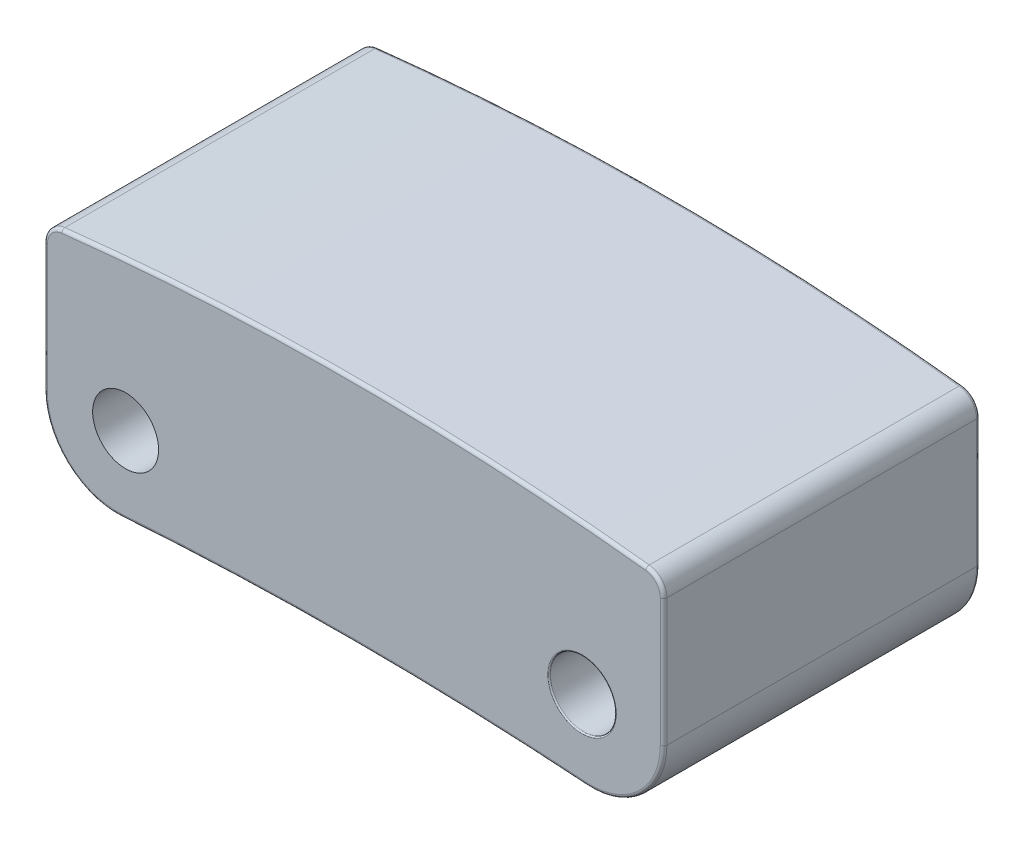
from build123d import *

# Parameters (mm, degrees)
SKETCH1_W               = 9.4
SKETCH1_H               = 3.7
BOSS_EXTRUDE1_DEPTH     = 2.4
CUT_EXTRUDE1_DEPTH      = 4.8
FILLET1_R               = 1.1
FILLET2_R               = 0.3
FILLET3_R               = 0.05
SKETCH3_R               = 0.5
CUT_EXTRUDE2_DEPTH      = 4.8
FILLET4_R               = 0.02
SKETCH4_W               = 1.881576533
SKETCH4_H               = 1.177564348
BOSS_EXTRUDE2_DEPTH     = 1
SKETCH5_R               = 0.5
CUT_EXTRUDE3_DEPTH      = 10
SKETCH6_R               = 0.737542503
BOSS_EXTRUDE3_DEPTH     = 1
CUT_EXTRUDE4_REACH      = 17.585
CUT_EXTRUDE4_END_RADIUS = 50.4
CUT_EXTRUDE4_START      = -10
SKETCH7_R               = 0.4
FILLET5_R               = 0.05


with BuildPart() as part:
    # Sketch1 → Boss-Extrude1 (new, symmetric)
    with BuildSketch(Plane.XY):
        Rectangle(SKETCH1_W, SKETCH1_H)
    extrude(amount=BOSS_EXTRUDE1_DEPTH, both=True)

    # Sketch2 → Cut-Extrude1 (cut)
    with BuildSketch(Plane.XY.offset(2.4)):
        with BuildLine():
            Line((-4.7, 1.55), (-7.120690005, 4.011417256))
            Line((-7.120690005, 4.011417256), (5.535860742, 3.886722174))
            Line((5.535860742, 3.886722174), (4.7, 1.55))
            ThreePointArc((4.7, 1.55), (0, 1.827084699), (-4.7, 1.55))
        make_face()
        with BuildLine():
            Line((4.7, -1.85), (0.350623614, -3.782025322))
            Line((0.350623614, -3.782025322), (-4.7, -1.85))
            ThreePointArc((-4.7, -1.85), (0, -1.628609864), (4.7, -1.85))
        make_face()
    extrude(amount=-CUT_EXTRUDE1_DEPTH, mode=Mode.SUBTRACT)

    # Fillet1
    fillet1_edges = [part.edges().sort_by_distance(p)[0] for p in [
        (4.7, -1.85, 0),
        (-4.7, -1.85, 0),
    ]]
    fillet(fillet1_edges, radius=FILLET1_R)

    # Fillet2
    fillet2_edges = [part.edges().sort_by_distance(p)[0] for p in [
        (4.7, 1.55, 0),
        (-4.7, 1.55, 0),
    ]]
    fillet(fillet2_edges, radius=FILLET2_R)

    # Fillet3
    fillet3_edges = [part.edges().sort_by_distance(p)[0] for p in [
        (4.7, 0.3134624, -2.4),
        (4.7, 0.3134624, 2.4),
        (0, -1.628609864, -2.4),
        (-4.349918456, -1.460327621, -2.4),
        (4.349918456, -1.460327621, -2.4),
        (0, -1.628609864, 2.4),
        (-4.349918456, -1.460327621, 2.4),
        (4.349918456, -1.460327621, 2.4),
        (0, 1.827084699, 2.4),
        (-4.7, 0.3134624, 2.4),
        (-4.623578634, 1.482534062, 2.4),
        (4.623578634, 1.482534062, 2.4),
        (0, 1.827084699, -2.4),
        (-4.7, 0.3134624, -2.4),
        (-4.623578634, 1.482534062, -2.4),
        (4.623578634, 1.482534062, -2.4),
    ]]
    fillet(fillet3_edges, radius=FILLET3_R)

    # Sketch3 → Cut-Extrude2 (cut)
    with BuildSketch(Plane.XY.offset(2.4)):
        with Locations((3.462563269, -0.578744651)):
            Circle(SKETCH3_R)
    cut_extrude2 = extrude(amount=-CUT_EXTRUDE2_DEPTH, mode=Mode.SUBTRACT)

    # Fillet4
    fillet4_edges = [part.edges().sort_by_distance(p)[0] for p in [
        (2.962563269, -0.578744651, -2.4),
        (2.962563269, -0.578744651, 2.4),
    ]]
    fillet(fillet4_edges, radius=FILLET4_R)

    # Mirror1: Cut-Extrude2 across plane
    add(cut_extrude2.mirror(Plane(origin=(0, 0, 0), x_dir=(0, 0, 1), z_dir=(1, 0, 0))), mode=Mode.SUBTRACT)

    # Sketch4 → Boss-Extrude2 (add)
    with BuildSketch(Plane.XY.offset(2.4)):
        with Locations((-3.353123346, -0.588782174)):
            Rectangle(SKETCH4_W, SKETCH4_H)
    extrude(amount=-BOSS_EXTRUDE2_DEPTH)

    # Sketch5 → Cut-Extrude3 (cut)
    with BuildSketch(Plane(origin=(0, 0, 1.4), x_dir=(-1, 0, 0), z_dir=(0, 0, -1))):
        with Locations(Location((3.462563269, -0.578744651, 0), (0, 0, 180))):
            Circle(SKETCH5_R)
    extrude(amount=-CUT_EXTRUDE3_DEPTH, mode=Mode.SUBTRACT)

    # Sketch6 → Boss-Extrude3 (add)
    with BuildSketch(Plane(origin=(0, 0, -2.4), x_dir=(-1, 0, 0), z_dir=(0, 0, -1))):
        with Locations((3.526657277, -0.607938651)):
            Circle(SKETCH6_R)
    extrude(amount=-BOSS_EXTRUDE3_DEPTH)

    # Cut-Extrude4: up to this cylinder (the profile starts inside it)
    cut_extrude4_end = Plane(origin=(0, -51.628609864, 0.9), z_dir=(0, 0, 1)) * Cylinder(CUT_EXTRUDE4_END_RADIUS, 136.97, mode=Mode.PRIVATE)
    # Sketch7 → Cut-Extrude4 (cut, up to the surface)
    with BuildSketch(Plane(origin=(0, 0, 0), x_dir=(1, 0, 0), z_dir=(0, 1, 0)).offset(CUT_EXTRUDE4_START), mode=Mode.PRIVATE) as cut_extrude4_sk1:
        with Locations(Location((-0.7, -0.9, 0), (0, 0, 90))):
            Circle(SKETCH7_R)
    cut_extrude4_tool1 = extrude(cut_extrude4_sk1.sketch, amount=CUT_EXTRUDE4_REACH, mode=Mode.PRIVATE) & cut_extrude4_end
    add(cut_extrude4_tool1.solids().sort_by_distance((-0.7, -10, 0.9))[0], mode=Mode.SUBTRACT)

    # Fillet5
    fillet5_edges = [part.edges().sort_by_distance(p)[0] for p in [
        (-0.700029875, -1.633510522, 1.299999999),
    ]]
    fillet(fillet5_edges, radius=FILLET5_R)


solid = part.part
